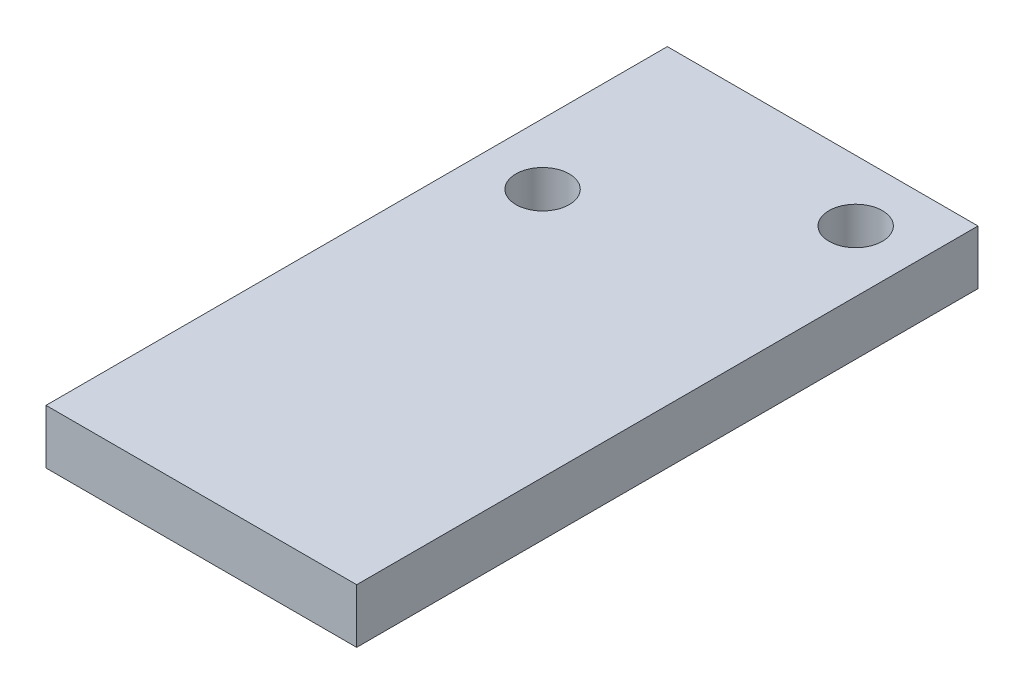
from build123d import *

# Parameters (mm, degrees)
SKETCH1_W           = 12.7
SKETCH1_H           = 25.4
SKETCH1_R           = 1.09
BOSS_EXTRUDE1_DEPTH = 2.22


with BuildPart() as part:
    # Sketch1 → Boss-Extrude1 (new body)
    with BuildSketch(Plane(origin=(0, 0, 0), x_dir=(1, 0, 0), z_dir=(0, 1, 0))):
        with Locations((6.35, 12.7)):
            Rectangle(SKETCH1_W, SKETCH1_H)
        with Locations((2.5, 17.8)):
            Circle(SKETCH1_R, mode=Mode.SUBTRACT)
        with Locations((10.2, 22.9)):
            Circle(SKETCH1_R, mode=Mode.SUBTRACT)
    extrude(amount=BOSS_EXTRUDE1_DEPTH)


solid = part.part
